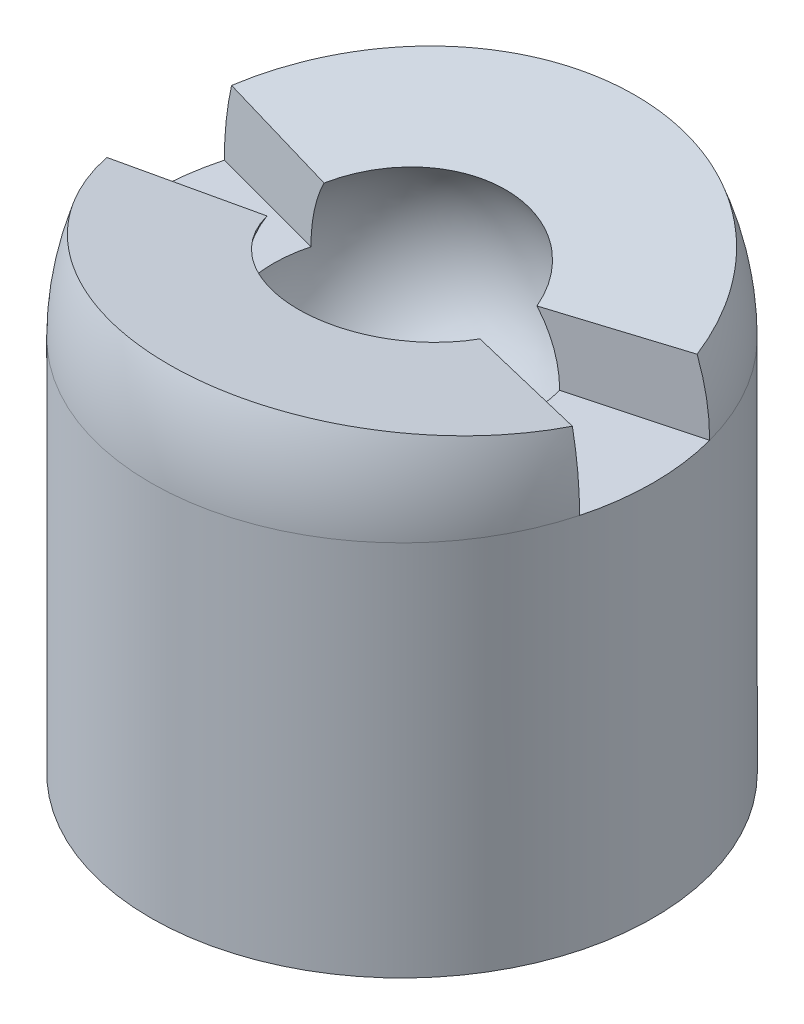
from build123d import *

# Parameters (mm, degrees)
SKETCH1_R           = 4
BOSS_EXTRUDE1_DEPTH = 10
FILLET2_R           = 4
CUT_EXTRUDE1_DEPTH  = 7.5
CUT_EXTRUDE2_DEPTH  = 15


with BuildPart() as part:
    # Sketch1 → Boss-Extrude1 (new body)
    with BuildSketch(Plane(origin=(0, 0, 0), x_dir=(1, 0, 0), z_dir=(0, 1, 0))):
        Circle(SKETCH1_R)
    extrude(amount=BOSS_EXTRUDE1_DEPTH)

    # Fillet2
    fillet2_edges = [part.edges().sort_by_distance(p)[0] for p in [
        (-4, 10, 0),
    ]]
    fillet(fillet2_edges, radius=FILLET2_R)

    # Sketch2 → Cut-Revolve1 (revolve, cut)
    with BuildSketch(Plane(origin=(0, 0, 0), x_dir=(0, 0, -1), z_dir=(1, 0, 0))):
        with BuildLine():
            Line((-2.05, 6), (2.05, 6))
            ThreePointArc((2.05, 6), (0, 3.95), (-2.05, 6))
        make_face()
    revolve(axis=Axis((0, 6, 2.05), (0, 0, -1)), mode=Mode.SUBTRACT)

    # Sketch3 → Cut-Extrude1 (cut, symmetric)
    with BuildSketch(Plane(origin=(0, 0, 0), x_dir=(0, 0, -1), z_dir=(1, 0, 0))):
        Polygon((0, 7), (24.021599864, 10.162503618), (-24.021599864, 10.162503618), align=None)
    extrude(amount=CUT_EXTRUDE1_DEPTH, both=True, mode=Mode.SUBTRACT)

    # Sketch4 → Cut-Extrude2 (cut)
    with BuildSketch(Plane(origin=(0, 6, 0), x_dir=(1, 0, 0), z_dir=(0, 1, 0))):
        Polygon((-0.557440617, 0.149365763), (-6.890783696, 1.846379926), (-6.890783696, -1.846379926), (-0.557440617, -0.149365763), align=None)
        Polygon((7.861288503, 2.106425906), (7.861288503, -2.106425906), (0.614333785, -0.164610242), (0.614333785, 0.164610242), align=None)
    extrude(amount=CUT_EXTRUDE2_DEPTH, mode=Mode.SUBTRACT)


solid = part.part
